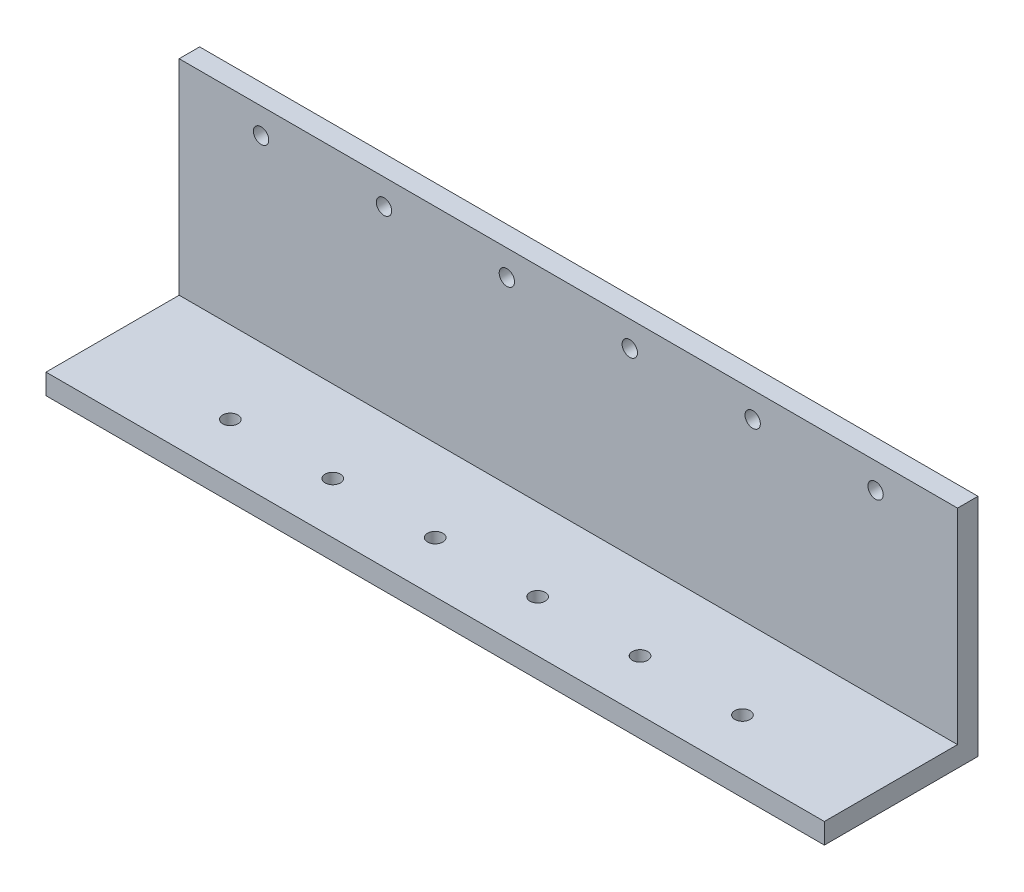
from build123d import *

# Parameters (mm, degrees)
SKETCH2_W           = 76
SKETCH2_H           = 20
SKETCH2_R           = 0.75
BOSS_EXTRUDE1_DEPTH = 2
SKETCH3_W           = 76
SKETCH3_H           = 15
SKETCH3_R           = 0.75
BOSS_EXTRUDE2_DEPTH = 2


with BuildPart() as part:
    # Sketch2 → Boss-Extrude1 (new body)
    with BuildSketch(Plane.XY):
        with Locations((38, 10)):
            Rectangle(SKETCH2_W, SKETCH2_H)
        with Locations((44, 17.5)):
            Circle(SKETCH2_R, mode=Mode.SUBTRACT)
        with Locations((56, 17.5)):
            Circle(SKETCH2_R, mode=Mode.SUBTRACT)
        with Locations((68, 17.5)):
            Circle(SKETCH2_R, mode=Mode.SUBTRACT)
        with Locations((32, 17.5)):
            Circle(SKETCH2_R, mode=Mode.SUBTRACT)
        with Locations((20, 17.5)):
            Circle(SKETCH2_R, mode=Mode.SUBTRACT)
        with Locations((8, 17.5)):
            Circle(SKETCH2_R, mode=Mode.SUBTRACT)
    extrude(amount=BOSS_EXTRUDE1_DEPTH)

    # Sketch3 → Boss-Extrude2 (add)
    with BuildSketch(Plane(origin=(0, 0, 0), x_dir=(-1, 0, 0), z_dir=(0, -1, 0))):
        with Locations((-38, -7.5)):
            Rectangle(SKETCH3_W, SKETCH3_H)
        with Locations((-13, -10)):
            Circle(SKETCH3_R, mode=Mode.SUBTRACT)
        with Locations((-23, -10)):
            Circle(SKETCH3_R, mode=Mode.SUBTRACT)
        with Locations((-33, -10)):
            Circle(SKETCH3_R, mode=Mode.SUBTRACT)
        with Locations((-43, -10)):
            Circle(SKETCH3_R, mode=Mode.SUBTRACT)
        with Locations((-53, -10)):
            Circle(SKETCH3_R, mode=Mode.SUBTRACT)
        with Locations((-63, -10)):
            Circle(SKETCH3_R, mode=Mode.SUBTRACT)
    extrude(amount=BOSS_EXTRUDE2_DEPTH)


solid = part.part
